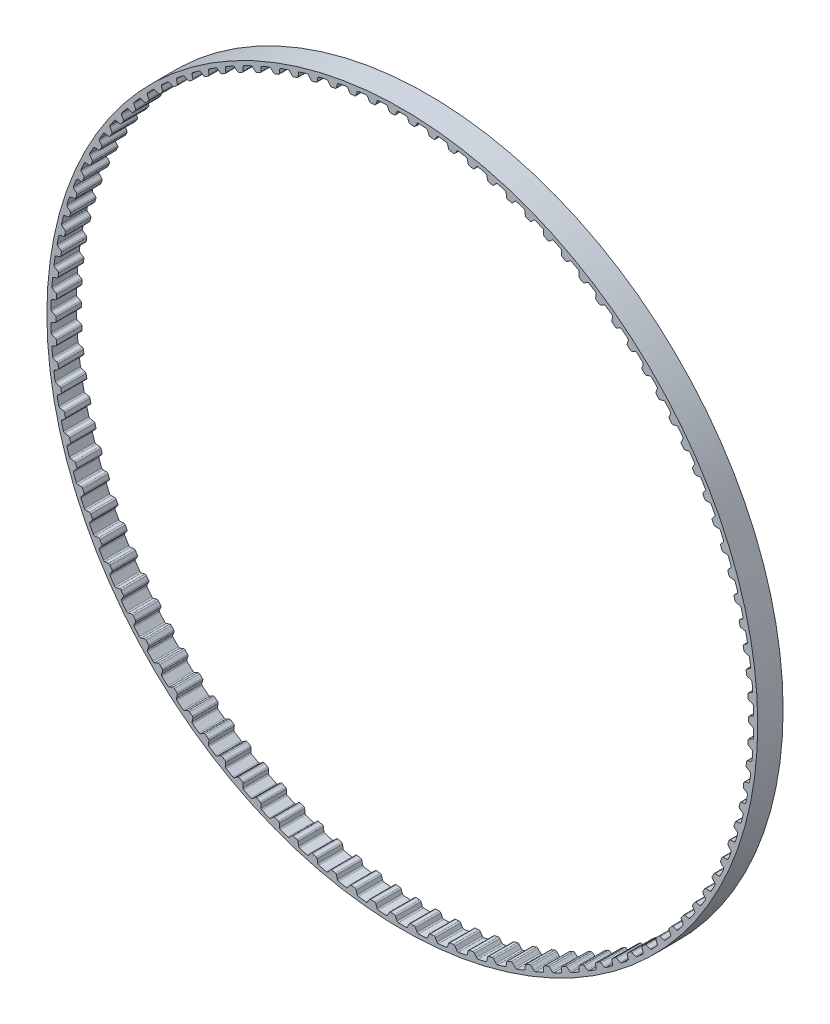
from build123d import *

# Parameters (mm, degrees)
SKETCH1_R           = 88.935857321
SKETCH1_R_2         = 86.649857321
BOSS_EXTRUDE1_DEPTH = 3.175
CUT_EXTRUDE1_DEPTH  = 3.175
CIRPATTERN1_COUNT   = 110


with BuildPart() as part:
    # Sketch1 → Boss-Extrude1 (new body, symmetric)
    with BuildSketch(Plane.XY):
        Circle(SKETCH1_R)
        Circle(SKETCH1_R_2, mode=Mode.SUBTRACT)
    extrude(amount=BOSS_EXTRUDE1_DEPTH, both=True)

    # Sketch3 → Cut-Extrude1 (cut, symmetric)
    with BuildSketch(Plane.XY):
        with BuildLine():
            Line((-2.024398903, 86.626206097), (2.024398903, 86.626206097))
            ThreePointArc((2.024398903, 86.626206097), (1.820316382, 86.691192473), (1.683539724, 86.856010706))
            Line((1.683539724, 86.856010706), (1.325640607, 87.684509009))
            ThreePointArc((1.325640607, 87.684509009), (1.186930267, 87.850622342), (0.980127507, 87.914393937))
            ThreePointArc((0.980127507, 87.914393937), (0, 87.919857321), (-0.980127507, 87.914393937))
            ThreePointArc((-0.980127507, 87.914393937), (-1.186930267, 87.850622342), (-1.325640607, 87.684509009))
            Line((-1.325640607, 87.684509009), (-1.683539724, 86.856010706))
            ThreePointArc((-1.683539724, 86.856010706), (-1.820316382, 86.691192473), (-2.024398903, 86.626206097))
        make_face()
    cut_extrude1 = extrude(amount=CUT_EXTRUDE1_DEPTH, both=True, mode=Mode.SUBTRACT)

    # CirPattern1: Cut-Extrude1 ×110 about axis
    cirpattern1_axis = Axis((0, 0, 0), (0, 0, 1))
    for i in range(1, CIRPATTERN1_COUNT):
        add(cut_extrude1.rotate(cirpattern1_axis, i * 360 / CIRPATTERN1_COUNT), mode=Mode.SUBTRACT)


solid = part.part
